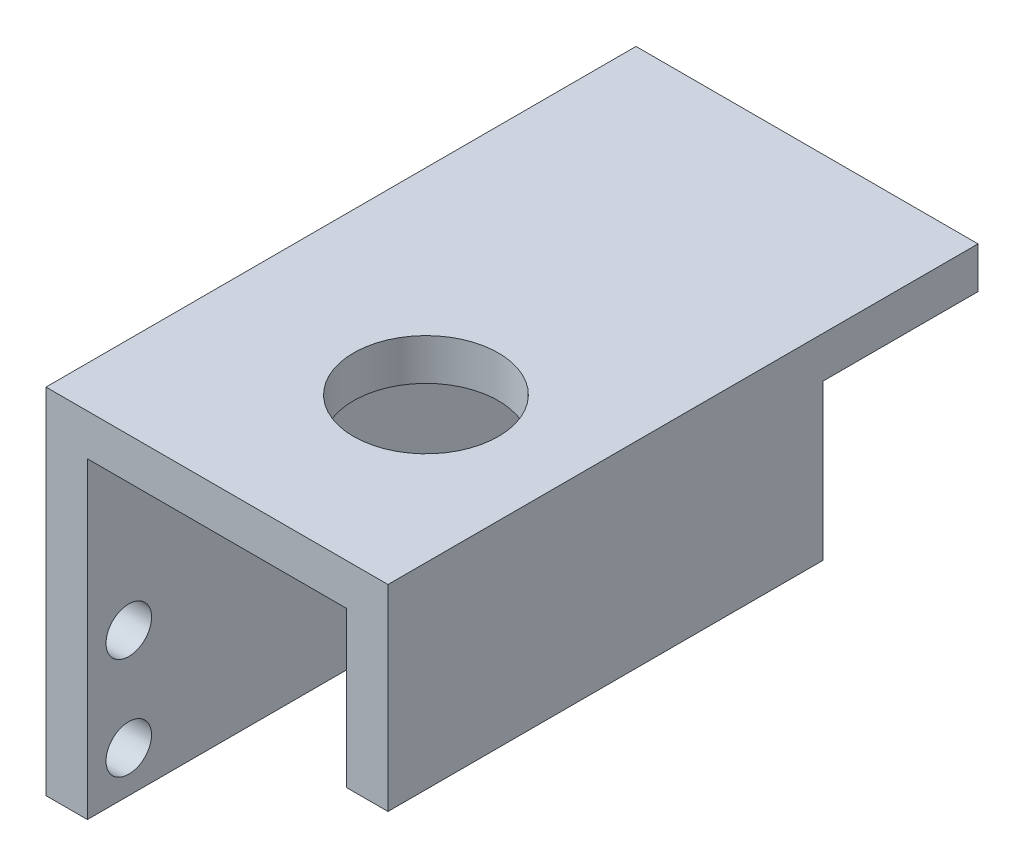
from build123d import *

# Parameters (mm, degrees)
SKETCH1_W           = 57.02
SKETCH1_H           = 34.2
SKETCH1_R           = 2.2
BOSS_EXTRUDE1_DEPTH = 4
SKETCH2_W           = 57.02
SKETCH2_H           = 4
BOSS_EXTRUDE2_DEPTH = 29.05
SKETCH3_W           = 4
SKETCH3_H           = 42.02
BOSS_EXTRUDE3_DEPTH = 15
SKETCH5_R           = 7
CUT_EXTRUDE1_DEPTH  = 4


with BuildPart() as part:
    # Sketch1 → Boss-Extrude1 (new body)
    with BuildSketch(Plane(origin=(0, 0, 0), x_dir=(0, 0, -1), z_dir=(1, 0, 0))):
        Rectangle(SKETCH1_W, SKETCH1_H)
        with Locations((-24.51, -3.25)):
            Circle(SKETCH1_R, mode=Mode.SUBTRACT)
        with Locations((-24.51, -13.1)):
            Circle(SKETCH1_R, mode=Mode.SUBTRACT)
        with Locations((24.51, -3.25)):
            Circle(SKETCH1_R, mode=Mode.SUBTRACT)
        with Locations((24.51, -13.1)):
            Circle(SKETCH1_R, mode=Mode.SUBTRACT)
    extrude(amount=BOSS_EXTRUDE1_DEPTH)

    # Sketch2 → Boss-Extrude2 (add)
    with BuildSketch(Plane(origin=(4, 0, 0), x_dir=(0, 0, -1), z_dir=(1, 0, 0))):
        with Locations((0, 15.1)):
            Rectangle(SKETCH2_W, SKETCH2_H)
    extrude(amount=BOSS_EXTRUDE2_DEPTH)

    # Sketch3 → Boss-Extrude3 (add)
    with BuildSketch(Plane.XZ.offset(-13.1)):
        with Locations((31.05, 7.5)):
            Rectangle(SKETCH3_W, SKETCH3_H)
    extrude(amount=BOSS_EXTRUDE3_DEPTH)

    # Sketch5 → Cut-Extrude1 (cut)
    with BuildSketch(Plane(origin=(0, 17.1, 0), x_dir=(1, 0, 0), z_dir=(0, 1, 0))):
        with Locations((19, -10.79)):
            Circle(SKETCH5_R)
    extrude(amount=-CUT_EXTRUDE1_DEPTH, mode=Mode.SUBTRACT)


solid = part.part
